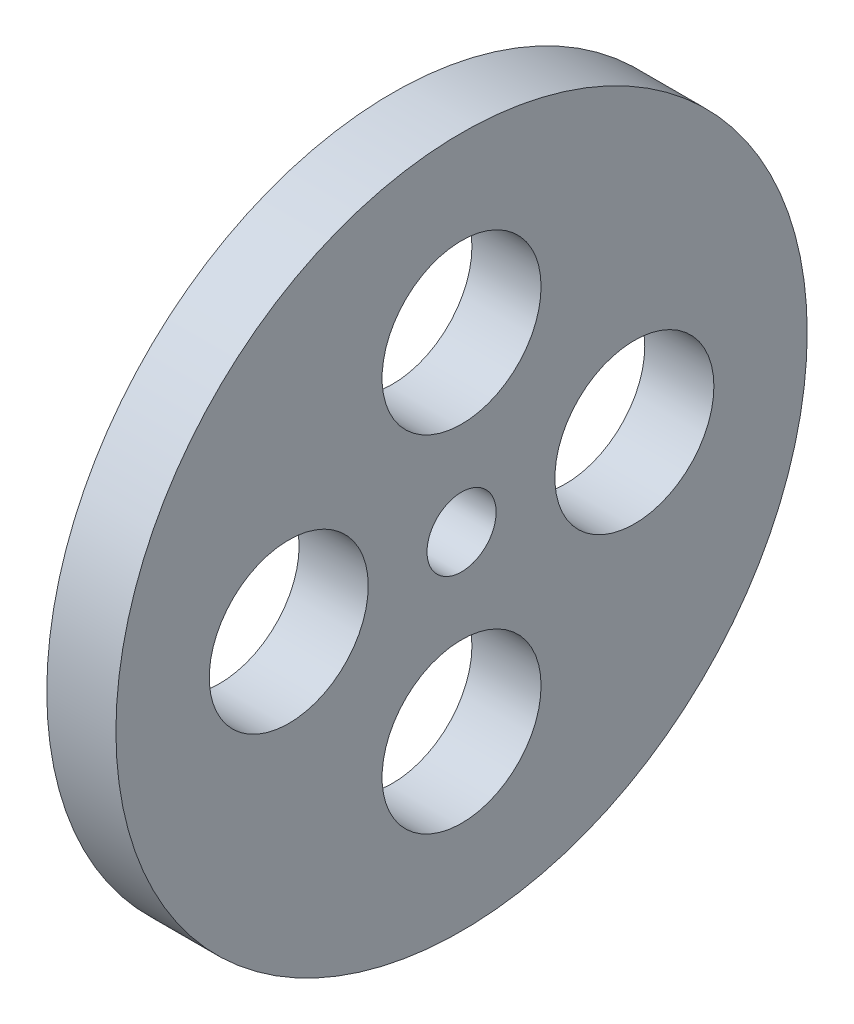
from build123d import *

# Parameters (mm, degrees)
SKETCH1_R           = 50
SKETCH1_R_2         = 5
SKETCH1_R_3         = 11.5
BOSS_EXTRUDE1_DEPTH = 10


with BuildPart() as part:
    # Sketch1 → Boss-Extrude1 (new body)
    with BuildSketch(Plane(origin=(0, 0, 0), x_dir=(0, 0, -1), z_dir=(1, 0, 0))):
        Circle(SKETCH1_R)
        Circle(SKETCH1_R_2, mode=Mode.SUBTRACT)
        with Locations((-25, 0)):
            Circle(SKETCH1_R_3, mode=Mode.SUBTRACT)
        with Locations((0, 25)):
            Circle(SKETCH1_R_3, mode=Mode.SUBTRACT)
        with Locations((25, 0)):
            Circle(SKETCH1_R_3, mode=Mode.SUBTRACT)
        with Locations((0, -25)):
            Circle(SKETCH1_R_3, mode=Mode.SUBTRACT)
    extrude(amount=BOSS_EXTRUDE1_DEPTH)


solid = part.part
